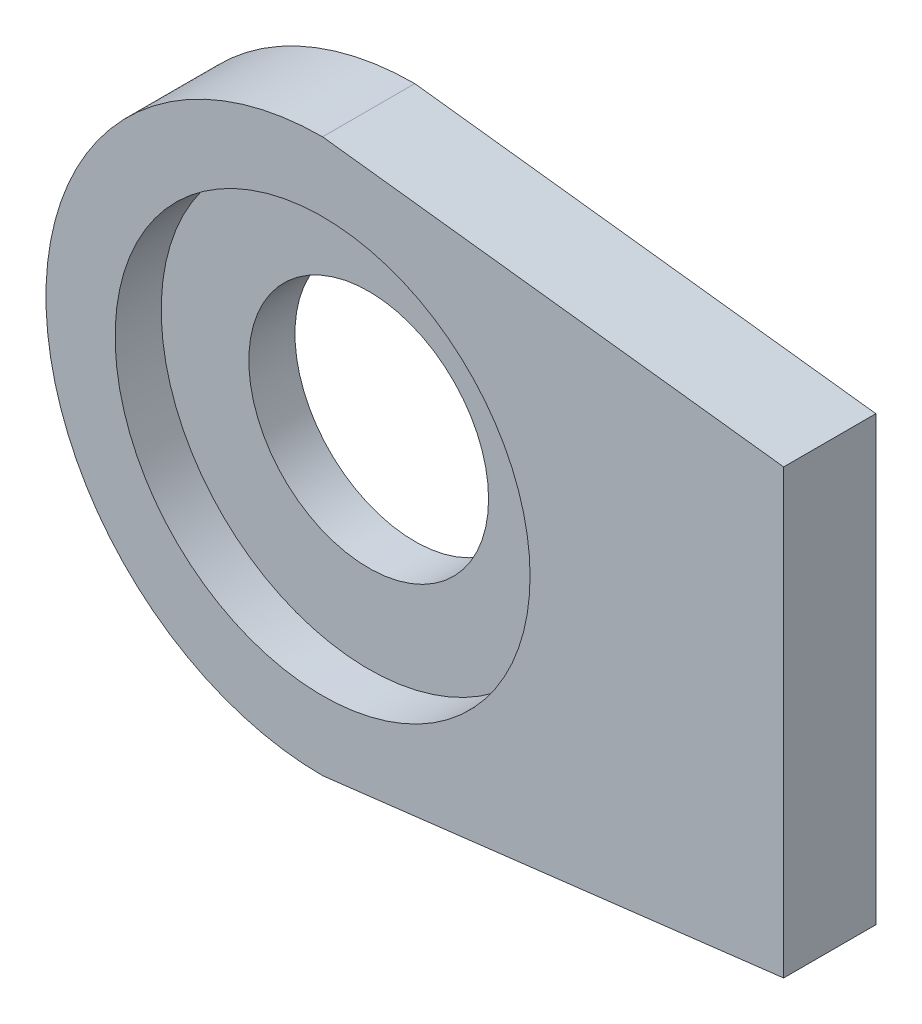
from build123d import *

# Parameters (mm, degrees)
BOSS_EXTRUDE1_DEPTH = 2
SKETCH5_R           = 2.6
CUT_EXTRUDE1_DEPTH  = 2
SKETCH6_R           = 4.5
CUT_EXTRUDE2_DEPTH  = 1


with BuildPart() as part:
    # Sketch2 → Boss-Extrude1 (new body)
    with BuildSketch(Plane.XY):
        with BuildLine():
            Line((10, -4.8), (10, 4.8))
            Line((10, 4.8), (0, 6))
            ThreePointArc((0, 6), (-6, 0), (0, -6))
            Line((0, -6), (10, -4.8))
        make_face()
    extrude(amount=BOSS_EXTRUDE1_DEPTH)

    # Sketch5 → Cut-Extrude1 (cut)
    with BuildSketch(Plane.XY.offset(2)):
        Circle(SKETCH5_R)
    extrude(amount=-CUT_EXTRUDE1_DEPTH, mode=Mode.SUBTRACT)

    # Sketch6 → Cut-Extrude2 (cut)
    with BuildSketch(Plane.XY.offset(2)):
        Circle(SKETCH6_R)
    extrude(amount=-CUT_EXTRUDE2_DEPTH, mode=Mode.SUBTRACT)


solid = part.part
